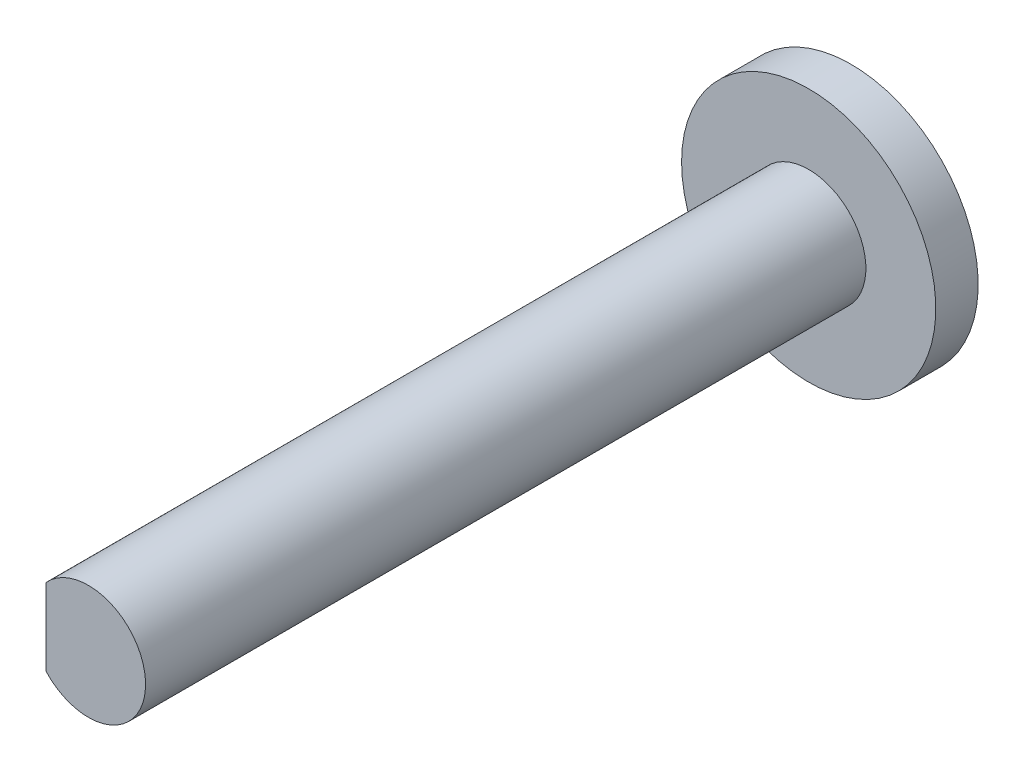
from build123d import *

# Parameters (mm, degrees)
SKETCH2_R           = 1.35
BOSS_EXTRUDE1_DEPTH = 8.5
CUT_EXTRUDE1_DEPTH  = 6.4
CUT_EXTRUDE2_DEPTH  = 3.2
SKETCH6_R           = 3
BOSS_EXTRUDE2_DEPTH = 1


with BuildPart() as part:
    # Sketch2 → Boss-Extrude1 (new body, symmetric)
    with BuildSketch(Plane.XY):
        Circle(SKETCH2_R)
    extrude(amount=BOSS_EXTRUDE1_DEPTH, both=True)

    # Sketch4 → Cut-Extrude1 (cut)
    with BuildSketch(Plane(origin=(0, 0, -8.5), x_dir=(-1, 0, 0), z_dir=(0, 0, -1))):
        with BuildLine():
            Line((1, 0.906917857), (1, -0.906917857))
            ThreePointArc((1, -0.906917857), (1.35, 0), (1, 0.906917857))
        make_face()
    extrude(amount=-CUT_EXTRUDE1_DEPTH, mode=Mode.SUBTRACT)

    # Sketch5 → Cut-Extrude2 (cut)
    with BuildSketch(Plane.XY.offset(8.5)):
        with BuildLine():
            Line((-1, 0.906917857), (-1, -0.906917857))
            ThreePointArc((-1, -0.906917857), (-1.35, 0), (-1, 0.906917857))
        make_face()
    extrude(amount=-CUT_EXTRUDE2_DEPTH, mode=Mode.SUBTRACT)

    # Sketch6 → Boss-Extrude2 (add)
    with BuildSketch(Plane(origin=(0, 0, -8.5), x_dir=(-1, 0, 0), z_dir=(0, 0, -1))):
        Circle(SKETCH6_R)
    extrude(amount=BOSS_EXTRUDE2_DEPTH)


solid = part.part
